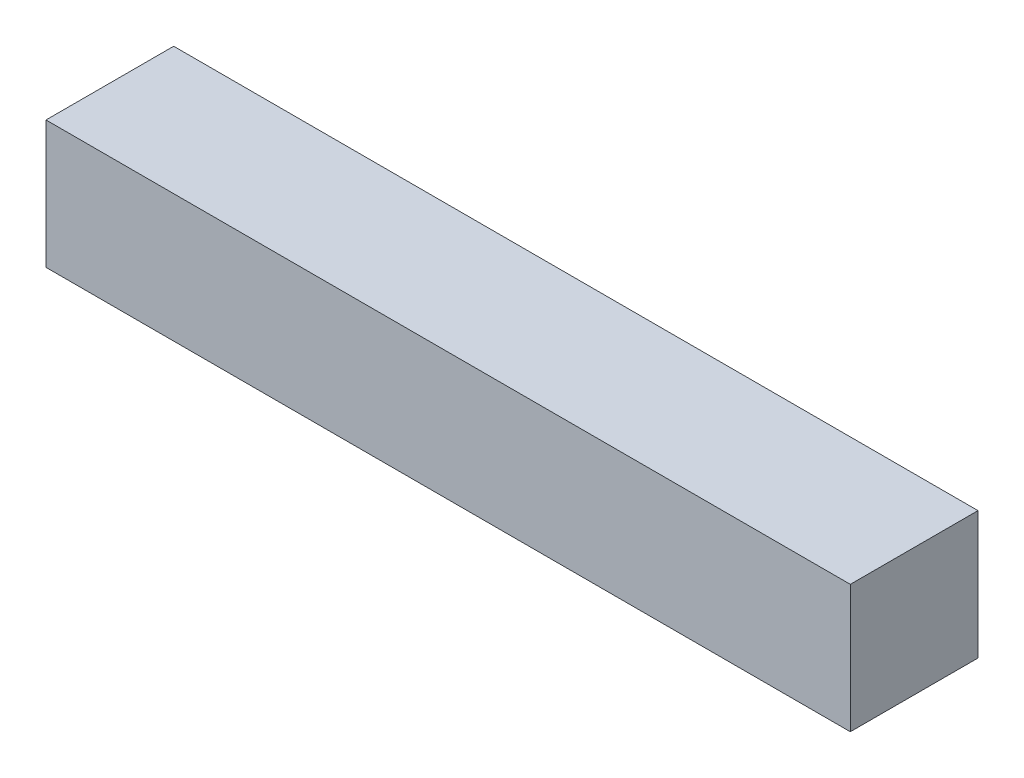
from build123d import *

# Parameters (mm, degrees)
SKETCH1_W           = 80
SKETCH1_H           = 12.7
BOSS_EXTRUDE1_DEPTH = 12.7


with BuildPart() as part:
    # Sketch1 → Boss-Extrude1 (new body)
    with BuildSketch(Plane(origin=(0, 0, 0), x_dir=(1, 0, 0), z_dir=(0, 1, 0))):
        Rectangle(SKETCH1_W, SKETCH1_H)
    extrude(amount=BOSS_EXTRUDE1_DEPTH)


solid = part.part
